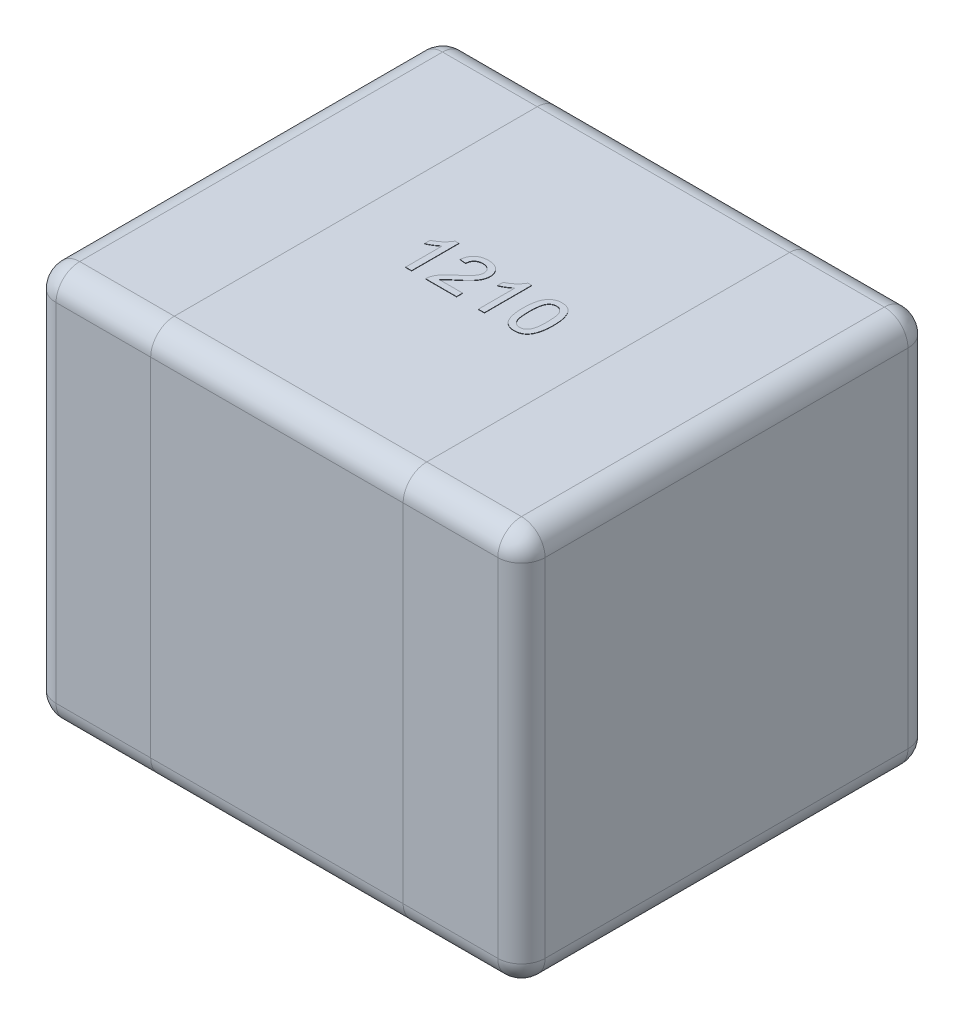
from build123d import *

# Parameters (mm, degrees)
SKETCH1_W      = 3.1
SKETCH1_H      = 2.6
EXTRUDE1_DEPTH = 2.5
FILLET1_R      = 0.15
EXTRUDE2_DEPTH = 0.002


with BuildPart() as part:
    # Sketch1 → Extrude1 (new body)
    with BuildSketch(Plane(origin=(0, 0, 0), x_dir=(1, 0, 0), z_dir=(0, 1, 0))):
        Rectangle(SKETCH1_W, SKETCH1_H)
    extrude(amount=EXTRUDE1_DEPTH)

    # Fillet1
    fillet1_edges = [part.edges().sort_by_distance(p)[0] for p in [
        (1.55, 2.5, 0),
        (0, 2.5, -1.3),
        (-1.55, 2.5, 0),
        (0, 0, -1.3),
        (1.55, 0, 0),
        (0, 0, 1.3),
        (-1.55, 0, 0),
        (0, 2.5, 1.3),
        (-1.55, 1.25, -1.3),
        (1.55, 1.25, -1.3),
        (1.55, 1.25, 1.3),
        (-1.55, 1.25, 1.3),
    ]]
    fillet(fillet1_edges, radius=FILLET1_R)

    # Sketch3 → Extrude2 (add)
    with BuildSketch(Plane(origin=(0, 2.5, 0), x_dir=(1, 0, 0), z_dir=(0, 1, 0))):
        with BuildLine():
            Line((-0.296153846, -0.15), (-0.334615385, -0.15))
            Line((-0.334615385, -0.15), (-0.334615385, 0.083774038))
            add(Edge.make_bspline(
                [(-0.334615385, 0.083774038), (-0.336830003, 0.081638311), (-0.341432846, 0.077199436), (-0.349213465, 0.070917319), (-0.35789763, 0.064550127), (-0.367372572, 0.05842736), (-0.377030672, 0.052663436), (-0.386363982, 0.047479672), (-0.39521668, 0.04309295), (-0.401047999, 0.040694273), (-0.403846154, 0.039543269)],
                knots=[0, 0, 0, 0, 9.226e-06, 1.9175e-05, 2.9969e-05, 4.1521e-05, 5.3002e-05, 6.3707e-05, 7.3544e-05, 8.2619e-05, 8.2619e-05, 8.2619e-05, 8.2619e-05], degree=3))
            Line((-0.403846154, 0.039543269), (-0.403846154, 0.075))
            add(Edge.make_bspline(
                [(-0.403846154, 0.075), (-0.399040034, 0.077475162), (-0.389567455, 0.082353558), (-0.37618475, 0.09077922), (-0.363690555, 0.099912985), (-0.352291699, 0.10975283), (-0.342073351, 0.119810917), (-0.333462201, 0.129959923), (-0.326256938, 0.139827828), (-0.322641922, 0.146709597), (-0.320913462, 0.15)],
                knots=[0, 0, 0, 0, 1.6212e-05, 3.1953e-05, 4.7386e-05, 6.26e-05, 7.7091e-05, 9.0349e-05, 0.000102505, 0.000113642, 0.000113642, 0.000113642, 0.000113642], degree=3))
            Line((-0.320913462, 0.15), (-0.296153846, 0.15))
            Line((-0.296153846, 0.15), (-0.296153846, -0.15))
        make_face()
        with BuildLine():
            Line((-0.011538462, -0.111538462), (-0.011538462, -0.15))
            Line((-0.011538462, -0.15), (-0.207692308, -0.15))
            add(Edge.make_bspline(
                [(-0.207692308, -0.15), (-0.207696323, -0.147714123), (-0.207704342, -0.14315003), (-0.206932024, -0.136400026), (-0.205722419, -0.129739566), (-0.204354719, -0.125468478), (-0.203665865, -0.123317308)],
                knots=[0, 0, 0, 0, 6.852e-06, 1.3681e-05, 2.0352e-05, 2.7121e-05, 2.7121e-05, 2.7121e-05, 2.7121e-05], degree=3))
            add(Edge.make_bspline(
                [(-0.203665865, -0.123317308), (-0.202393093, -0.119802551), (-0.199801518, -0.112645929), (-0.19455096, -0.102319922), (-0.188375063, -0.092056365), (-0.182361958, -0.08370038), (-0.176855252, -0.077024532), (-0.172237162, -0.071801454), (-0.167119471, -0.066455018), (-0.161506278, -0.060986201), (-0.155451607, -0.055359583), (-0.148947197, -0.049556401), (-0.141916239, -0.043684801), (-0.137007895, -0.039792861), (-0.134495192, -0.037800481)],
                knots=[0, 0, 0, 0, 1.1205e-05, 2.2816e-05, 3.4678e-05, 4.712e-05, 5.3653e-05, 6.0635e-05, 6.8031e-05, 7.5851e-05, 8.4142e-05, 9.2826e-05, 0.000101998, 0.000111618, 0.000111618, 0.000111618, 0.000111618], degree=3))
            add(Edge.make_bspline(
                [(-0.134495192, -0.037800481), (-0.130635061, -0.034551471), (-0.123202132, -0.028295295), (-0.112705672, -0.019011711), (-0.103118865, -0.010391377), (-0.094594368, -0.002283205), (-0.087062462, 0.005234162), (-0.080505461, 0.012143692), (-0.074866946, 0.018423822), (-0.070215752, 0.024301865), (-0.066291398, 0.029852373), (-0.062965854, 0.035266551), (-0.060194454, 0.040638972), (-0.057886249, 0.045952637), (-0.056060655, 0.05123027), (-0.054816253, 0.056487246), (-0.053972343, 0.061671403), (-0.053887909, 0.065120999), (-0.053846154, 0.066826923)],
                knots=[0, 0, 0, 0, 1.5136e-05, 2.9145e-05, 4.2036e-05, 5.3811e-05, 6.4435e-05, 7.3957e-05, 8.2386e-05, 8.9745e-05, 9.643e-05, 0.000102769, 0.00010879, 0.00011455, 0.000120137, 0.000125516, 0.000130743, 0.000135857, 0.000135857, 0.000135857, 0.000135857], degree=3))
            add(Edge.make_bspline(
                [(-0.053846154, 0.066826923), (-0.053887914, 0.068512943), (-0.053969845, 0.071820821), (-0.054747201, 0.076661881), (-0.055829343, 0.081323937), (-0.057578837, 0.085723063), (-0.059661262, 0.089989532), (-0.062332474, 0.093988532), (-0.065422517, 0.097819726), (-0.068960356, 0.101382104), (-0.072824504, 0.104724183), (-0.077142138, 0.107502263), (-0.081629679, 0.110003363), (-0.086441941, 0.11201439), (-0.091571106, 0.113491124), (-0.096979835, 0.114562852), (-0.10266727, 0.115242385), (-0.106548545, 0.115336486), (-0.108533654, 0.115384615)],
                knots=[0, 0, 0, 0, 5.054e-06, 9.915e-06, 1.4681e-05, 1.938e-05, 2.4083e-05, 2.89e-05, 3.3772e-05, 3.8829e-05, 4.3946e-05, 4.9063e-05, 5.4199e-05, 5.9345e-05, 6.4669e-05, 7.0185e-05, 7.5872e-05, 8.1827e-05, 8.1827e-05, 8.1827e-05, 8.1827e-05], degree=3))
            add(Edge.make_bspline(
                [(-0.108533654, 0.115384615), (-0.110618956, 0.115336725), (-0.114700045, 0.115242999), (-0.120665504, 0.114560756), (-0.126328674, 0.113518381), (-0.131676037, 0.111924678), (-0.136701084, 0.109917004), (-0.141383351, 0.107389877), (-0.145797819, 0.104537208), (-0.149805459, 0.101159863), (-0.153429516, 0.097415076), (-0.156646835, 0.093338135), (-0.159282944, 0.088850365), (-0.161459952, 0.084050442), (-0.163210448, 0.078923275), (-0.164481249, 0.07342967), (-0.165174098, 0.067585487), (-0.165313425, 0.063583392), (-0.165384615, 0.061538462)],
                knots=[0, 0, 0, 0, 6.255e-06, 1.2241e-05, 1.7992e-05, 2.3507e-05, 2.8953e-05, 3.4195e-05, 3.9446e-05, 4.4693e-05, 4.9878e-05, 5.506e-05, 6.0233e-05, 6.5451e-05, 7.0848e-05, 7.6461e-05, 8.2334e-05, 8.8471e-05, 8.8471e-05, 8.8471e-05, 8.8471e-05], degree=3))
            Line((-0.165384615, 0.061538462), (-0.203846154, 0.065384615))
            add(Edge.make_bspline(
                [(-0.203846154, 0.065384615), (-0.203452638, 0.068736632), (-0.202687086, 0.075257693), (-0.200780201, 0.084702351), (-0.198103106, 0.09348859), (-0.194899737, 0.101738909), (-0.190884012, 0.109312863), (-0.18634458, 0.11636711), (-0.18099053, 0.122677919), (-0.175075725, 0.128444216), (-0.168535362, 0.133525841), (-0.161430878, 0.137965346), (-0.153765522, 0.141678718), (-0.145581988, 0.144753235), (-0.136861488, 0.147085948), (-0.12761636, 0.148758724), (-0.117831734, 0.149789842), (-0.111120341, 0.149928948), (-0.107692308, 0.15)],
                knots=[0, 0, 0, 0, 1.0123e-05, 1.9693e-05, 2.8857e-05, 3.7651e-05, 4.6199e-05, 5.4533e-05, 6.2766e-05, 7.0968e-05, 7.9275e-05, 8.7563e-05, 9.6056e-05, 0.000104785, 0.00011375, 0.000123098, 0.000132946, 0.000143229, 0.000143229, 0.000143229, 0.000143229], degree=3))
            add(Edge.make_bspline(
                [(-0.107692308, 0.15), (-0.104223243, 0.149940596), (-0.097465484, 0.149824877), (-0.087618344, 0.14864084), (-0.078327294, 0.146796713), (-0.069558275, 0.144226564), (-0.061363096, 0.140856333), (-0.053735451, 0.136738671), (-0.046640172, 0.131913745), (-0.040195807, 0.126323636), (-0.034384754, 0.120221095), (-0.029292223, 0.113708369), (-0.025034622, 0.106813279), (-0.021409539, 0.09962981), (-0.018720681, 0.092006182), (-0.016829827, 0.084046037), (-0.015544936, 0.075742575), (-0.015438766, 0.070077103), (-0.015384615, 0.0671875)],
                knots=[0, 0, 0, 0, 1.0403e-05, 2.0265e-05, 2.9705e-05, 3.8794e-05, 4.7633e-05, 5.6238e-05, 6.4755e-05, 7.3321e-05, 8.178e-05, 9.0002e-05, 9.8073e-05, 0.000106055, 0.000114096, 0.000122258, 0.000130579, 0.00013924, 0.00013924, 0.00013924, 0.00013924], degree=3))
            add(Edge.make_bspline(
                [(-0.015384615, 0.0671875), (-0.015467303, 0.06421876), (-0.01563286, 0.058274728), (-0.016925056, 0.049390154), (-0.019136019, 0.040601997), (-0.022067165, 0.0318033), (-0.026071721, 0.022959142), (-0.031130797, 0.013947517), (-0.037407134, 0.004735138), (-0.04344321, -0.003096409), (-0.049061817, -0.009661219), (-0.054042181, -0.015064442), (-0.059804175, -0.020805005), (-0.066131643, -0.027081717), (-0.073282651, -0.033671804), (-0.081051734, -0.040772611), (-0.089608959, -0.048197271), (-0.095549342, -0.053269443), (-0.098617788, -0.055889423)],
                knots=[0, 0, 0, 0, 8.904e-06, 1.7828e-05, 2.6865e-05, 3.6063e-05, 4.5612e-05, 5.5944e-05, 6.7028e-05, 7.9024e-05, 8.5588e-05, 9.2946e-05, 0.000101063, 0.000109987, 0.000119681, 0.000130232, 0.000141562, 0.000153666, 0.000153666, 0.000153666, 0.000153666], degree=3))
            add(Edge.make_bspline(
                [(-0.098617788, -0.055889423), (-0.101245449, -0.058028619), (-0.106255994, -0.062107737), (-0.113384465, -0.068021343), (-0.119769407, -0.07344396), (-0.12556013, -0.078198712), (-0.130545741, -0.08251558), (-0.13490185, -0.086205504), (-0.138470198, -0.089454013), (-0.14390416, -0.094388563), (-0.150786737, -0.101422266), (-0.155858114, -0.108256719), (-0.158293269, -0.111538462)],
                knots=[0, 0, 0, 0, 1.0165e-05, 1.9383e-05, 2.7786e-05, 3.5295e-05, 4.1859e-05, 4.7569e-05, 5.242e-05, 5.6334e-05, 6.9594e-05, 8.1844e-05, 8.1844e-05, 8.1844e-05, 8.1844e-05], degree=3))
            Line((-0.158293269, -0.111538462), (-0.011538462, -0.111538462))
        make_face()
        with BuildLine():
            Line((0.165384615, -0.15), (0.126923077, -0.15))
            Line((0.126923077, -0.15), (0.126923077, 0.083774038))
            add(Edge.make_bspline(
                [(0.126923077, 0.083774038), (0.124708458, 0.081638311), (0.120105616, 0.077199436), (0.112324997, 0.070917319), (0.103640832, 0.064550127), (0.09416589, 0.05842736), (0.08450779, 0.052663436), (0.075174479, 0.047479672), (0.066321782, 0.04309295), (0.060490463, 0.040694273), (0.057692308, 0.039543269)],
                knots=[0, 0, 0, 0, 9.226e-06, 1.9175e-05, 2.9969e-05, 4.1521e-05, 5.3002e-05, 6.3707e-05, 7.3544e-05, 8.2619e-05, 8.2619e-05, 8.2619e-05, 8.2619e-05], degree=3))
            Line((0.057692308, 0.039543269), (0.057692308, 0.075))
            add(Edge.make_bspline(
                [(0.057692308, 0.075), (0.062498428, 0.077475162), (0.071971006, 0.082353558), (0.085353711, 0.09077922), (0.097847906, 0.099912985), (0.109246762, 0.10975283), (0.11946511, 0.119810917), (0.128076261, 0.129959923), (0.135281523, 0.139827828), (0.13889654, 0.146709597), (0.140625, 0.15)],
                knots=[0, 0, 0, 0, 1.6212e-05, 3.1953e-05, 4.7386e-05, 6.26e-05, 7.7091e-05, 9.0349e-05, 0.000102505, 0.000113642, 0.000113642, 0.000113642, 0.000113642], degree=3))
            Line((0.140625, 0.15), (0.165384615, 0.15))
            Line((0.165384615, 0.15), (0.165384615, -0.15))
        make_face()
        with BuildLine():
            add(Edge.make_bspline(
                [(0.261538462, -0.002043269), (0.261577212, 0.002244006), (0.261653106, 0.010640973), (0.262123858, 0.022927244), (0.262945753, 0.034595007), (0.264172615, 0.045634129), (0.265625449, 0.056069528), (0.267514143, 0.06588631), (0.269639198, 0.075106502), (0.272188883, 0.083720493), (0.274990152, 0.091802347), (0.278168281, 0.0993391), (0.281744108, 0.106322761), (0.285541902, 0.112825754), (0.289761587, 0.118746931), (0.294148472, 0.124252464), (0.299021369, 0.129140445), (0.304177653, 0.13353664), (0.309693251, 0.137416027), (0.31553898, 0.140763469), (0.321692348, 0.143719019), (0.32827063, 0.145943957), (0.335137264, 0.147757753), (0.342345104, 0.149092003), (0.349902094, 0.149878588), (0.355066234, 0.149959072), (0.357692308, 0.15)],
                knots=[0, 0, 0, 0, 1.2862e-05, 2.5191e-05, 3.688e-05, 4.7943e-05, 5.8507e-05, 6.8478e-05, 7.7924e-05, 8.6881e-05, 9.5415e-05, 0.000103574, 0.000111395, 0.00011894, 0.000126142, 0.000133191, 0.000140033, 0.000146812, 0.000153498, 0.000160229, 0.000167003, 0.000173941, 0.000181025, 0.000188297, 0.00019591, 0.000203786, 0.000203786, 0.000203786, 0.000203786], degree=3))
            add(Edge.make_bspline(
                [(0.357692308, 0.15), (0.361545099, 0.149886731), (0.369114062, 0.149664209), (0.380164787, 0.147849358), (0.390579383, 0.144744777), (0.400351085, 0.140556563), (0.409312845, 0.135236725), (0.417316074, 0.128769652), (0.424274445, 0.121223246), (0.430112018, 0.112508085), (0.435214639, 0.102864591), (0.439747696, 0.092249481), (0.443845448, 0.080674651), (0.446753302, 0.070313561), (0.448827472, 0.061369501), (0.450200407, 0.053992694), (0.451340219, 0.046033077), (0.452213469, 0.037509907), (0.45292995, 0.028432744), (0.453483255, 0.018795935), (0.453764114, 0.008575397), (0.453818295, 0.001562641), (0.453846154, -0.002043269)],
                knots=[0, 0, 0, 0, 1.1554e-05, 2.2698e-05, 3.348e-05, 4.4085e-05, 5.4516e-05, 6.4643e-05, 7.485e-05, 8.5185e-05, 9.602e-05, 0.000107541, 0.000119781, 0.000132832, 0.000139801, 0.000147321, 0.000155335, 0.000163916, 0.000173019, 0.00018265, 0.000192871, 0.000203689, 0.000203689, 0.000203689, 0.000203689], degree=3))
            add(Edge.make_bspline(
                [(0.453846154, -0.002043269), (0.453806678, -0.006310407), (0.453729554, -0.0146471), (0.453271416, -0.026834856), (0.452399997, -0.038414591), (0.4513277, -0.049412832), (0.449705539, -0.059800218), (0.447957572, -0.069620882), (0.445795769, -0.07883023), (0.443273453, -0.087432298), (0.440432752, -0.095472571), (0.437317483, -0.103011813), (0.433867025, -0.110044871), (0.429978677, -0.11650315), (0.425830349, -0.122472371), (0.42139166, -0.127974928), (0.416568504, -0.132931621), (0.411365754, -0.137314631), (0.405888882, -0.141262812), (0.400028941, -0.144643304), (0.393811578, -0.147443983), (0.387278334, -0.149838424), (0.38036292, -0.15159293), (0.37311987, -0.152935977), (0.365522497, -0.153726861), (0.360338382, -0.153805841), (0.357692308, -0.153846154)],
                knots=[0, 0, 0, 0, 1.2802e-05, 2.5011e-05, 3.658e-05, 4.7637e-05, 5.815e-05, 6.811e-05, 7.7556e-05, 8.6513e-05, 9.499e-05, 0.000103126, 0.000110974, 0.000118467, 0.000125719, 0.000132767, 0.000139652, 0.000146431, 0.000153152, 0.000159883, 0.000166686, 0.000173587, 0.000180729, 0.000188061, 0.000195673, 0.00020361, 0.00020361, 0.00020361, 0.00020361], degree=3))
            add(Edge.make_bspline(
                [(0.357692308, -0.153846154), (0.354222998, -0.153747192), (0.347458799, -0.153554242), (0.337580184, -0.152243272), (0.328308578, -0.149935902), (0.319565779, -0.146841394), (0.311450058, -0.142702311), (0.303922667, -0.137666308), (0.296832347, -0.131850554), (0.292750728, -0.127262057), (0.290685096, -0.124939904)],
                knots=[0, 0, 0, 0, 1.0408e-05, 2.0292e-05, 2.9825e-05, 3.9025e-05, 4.8056e-05, 5.7073e-05, 6.616e-05, 7.5471e-05, 7.5471e-05, 7.5471e-05, 7.5471e-05], degree=3))
            add(Edge.make_bspline(
                [(0.290685096, -0.124939904), (0.288307506, -0.121510195), (0.283404814, -0.11443799), (0.277666637, -0.102379223), (0.272548083, -0.089104214), (0.268530955, -0.074352508), (0.265384543, -0.058241513), (0.263112049, -0.040739616), (0.26182604, -0.021854376), (0.261636485, -0.008796046), (0.261538462, -0.002043269)],
                knots=[0, 0, 0, 0, 1.2501e-05, 2.5778e-05, 3.993e-05, 5.5152e-05, 7.157e-05, 8.9147e-05, 0.000108063, 0.000128321, 0.000128321, 0.000128321, 0.000128321], degree=3))
        make_face()
        with BuildLine():
            add(Edge.make_bspline(
                [(0.3, -0.001923077), (0.300038189, -0.007693168), (0.300111292, -0.018738399), (0.300875037, -0.034518417), (0.302189794, -0.048754147), (0.303927988, -0.061425879), (0.306223107, -0.072550754), (0.309104901, -0.082100422), (0.312353369, -0.090189501), (0.316373285, -0.096717734), (0.32077465, -0.102039196), (0.325318759, -0.106615825), (0.330112518, -0.110505855), (0.335124649, -0.113749347), (0.340432919, -0.116205105), (0.345979283, -0.117985045), (0.351764947, -0.119009373), (0.355705248, -0.119156549), (0.357692308, -0.119230769)],
                knots=[0, 0, 0, 0, 1.7309e-05, 3.3134e-05, 4.7378e-05, 6.0186e-05, 7.1489e-05, 8.1413e-05, 9.0085e-05, 9.7558e-05, 0.000104306, 0.000110765, 0.000116876, 0.000122794, 0.000128628, 0.000134368, 0.000140227, 0.000146187, 0.000146187, 0.000146187, 0.000146187], degree=3))
            add(Edge.make_bspline(
                [(0.357692308, -0.119230769), (0.35967887, -0.119154928), (0.363618184, -0.119004535), (0.369417217, -0.118002795), (0.374942001, -0.116131225), (0.380242356, -0.11368414), (0.385290917, -0.110514577), (0.390061133, -0.106609854), (0.394629179, -0.102035942), (0.399010773, -0.096652628), (0.403000063, -0.090094213), (0.406309468, -0.082011723), (0.409146351, -0.072445331), (0.411454064, -0.061326124), (0.413199428, -0.048674427), (0.414506235, -0.03447818), (0.415275092, -0.018718466), (0.415346988, -0.007693194), (0.415384615, -0.001923077)],
                knots=[0, 0, 0, 0, 5.96e-06, 1.1819e-05, 1.7578e-05, 2.3412e-05, 2.9298e-05, 3.5408e-05, 4.1867e-05, 4.8662e-05, 5.6186e-05, 6.4803e-05, 7.4784e-05, 8.6088e-05, 9.8836e-05, 0.00011308, 0.000128845, 0.000146154, 0.000146154, 0.000146154, 0.000146154], degree=3))
            add(Edge.make_bspline(
                [(0.415384615, -0.001923077), (0.415348193, 0.003726983), (0.415278409, 0.014552283), (0.414489723, 0.030028299), (0.41325378, 0.044025088), (0.411563207, 0.056555555), (0.409316435, 0.067606095), (0.406591408, 0.077200235), (0.403344131, 0.085317512), (0.39948313, 0.092039466), (0.395185063, 0.097553292), (0.390695324, 0.102325988), (0.385901671, 0.10638501), (0.380719172, 0.109641218), (0.375314872, 0.112268205), (0.369564591, 0.114076165), (0.363524851, 0.115186918), (0.359379855, 0.115317963), (0.357271635, 0.115384615)],
                knots=[0, 0, 0, 0, 1.6949e-05, 3.2473e-05, 4.6473e-05, 5.9094e-05, 7.0385e-05, 8.0274e-05, 8.8979e-05, 9.6545e-05, 0.000103444, 0.000109906, 0.000116177, 0.000122229, 0.000128223, 0.000134153, 0.000140259, 0.000146579, 0.000146579, 0.000146579, 0.000146579], degree=3))
            add(Edge.make_bspline(
                [(0.357271635, 0.115384615), (0.355284699, 0.115332466), (0.351366718, 0.115229635), (0.34563028, 0.114248109), (0.340193925, 0.112606778), (0.33499537, 0.110383437), (0.330164394, 0.107391258), (0.325509413, 0.103897677), (0.321248448, 0.099641138), (0.318680828, 0.096459016), (0.317367788, 0.094831731)],
                knots=[0, 0, 0, 0, 5.957e-06, 1.1747e-05, 1.7393e-05, 2.2965e-05, 2.8654e-05, 3.4399e-05, 4.0391e-05, 4.6662e-05, 4.6662e-05, 4.6662e-05, 4.6662e-05], degree=3))
            add(Edge.make_bspline(
                [(0.317367788, 0.094831731), (0.315938289, 0.092441753), (0.312919488, 0.087394622), (0.309541626, 0.078622501), (0.306557755, 0.068597636), (0.30410104, 0.057165788), (0.30232378, 0.044346567), (0.300920701, 0.03015486), (0.300191854, 0.014570853), (0.300065716, 0.003726591), (0.3, -0.001923077)],
                knots=[0, 0, 0, 0, 8.341e-06, 1.7615e-05, 2.8091e-05, 3.9714e-05, 5.2649e-05, 6.6899e-05, 8.2483e-05, 9.9433e-05, 9.9433e-05, 9.9433e-05, 9.9433e-05], degree=3))
        make_face(mode=Mode.SUBTRACT)
    extrude(amount=EXTRUDE2_DEPTH)


solid = part.part
